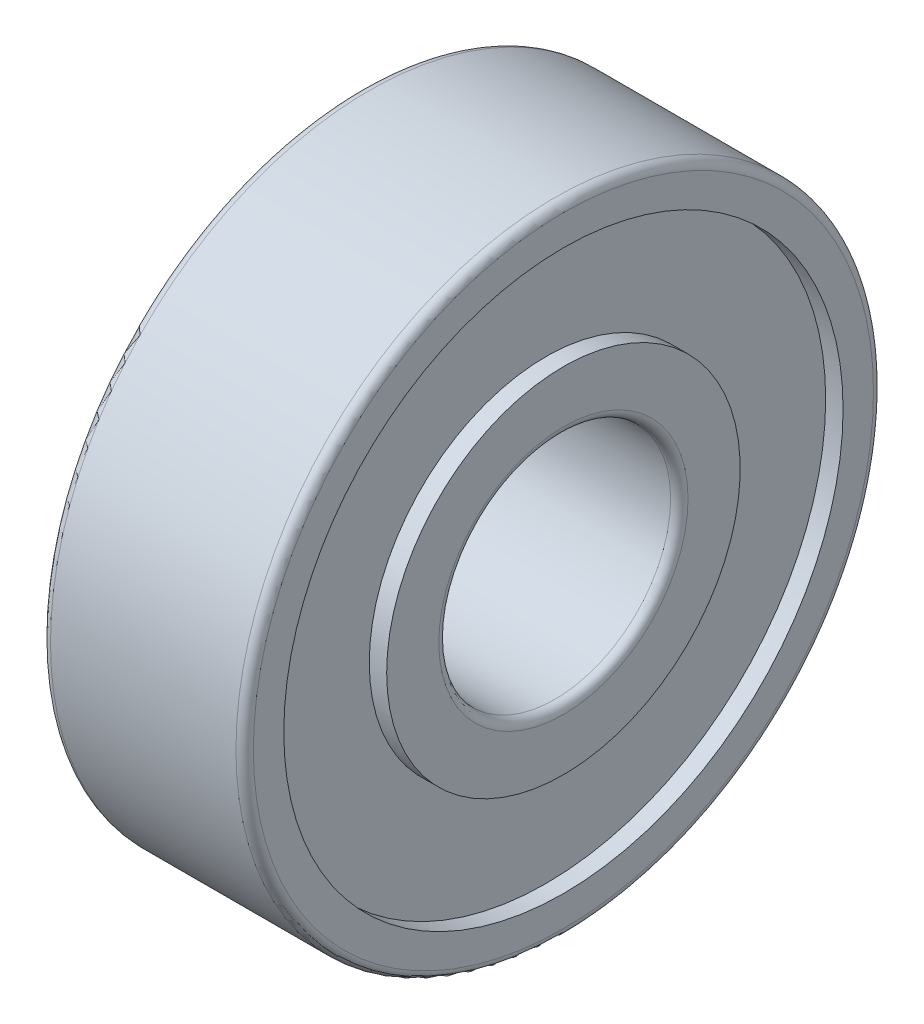
from build123d import *

# Parameters (mm, degrees)
FILLET1_R = 0.3
FILLET2_R = 0.3


with BuildPart() as part:
    # Sketch1 → Revolve1 (revolve)
    with BuildSketch(Plane.XY):
        Polygon((-7, 4), (0, 4), (0, 6.1), (-0.6, 6.1), (-0.6, 9.65), (0, 9.65), (0, 11), (-7, 11), (-7, 9.65), (-6.4, 9.65), (-6.4, 6.1), (-7, 6.1), align=None)
    revolve(axis=Axis((-7, 0, 0), (1, 0, 0)))

    # Fillet1
    fillet1_edges = [part.edges().sort_by_distance(p)[0] for p in [
        (-7, -11, 0),
        (0, -11, 0),
    ]]
    fillet(fillet1_edges, radius=FILLET1_R)

    # Fillet2
    fillet2_edges = [part.edges().sort_by_distance(p)[0] for p in [
        (0, -4, 0),
        (-7, -4, 0),
    ]]
    fillet(fillet2_edges, radius=FILLET2_R)


solid = part.part
